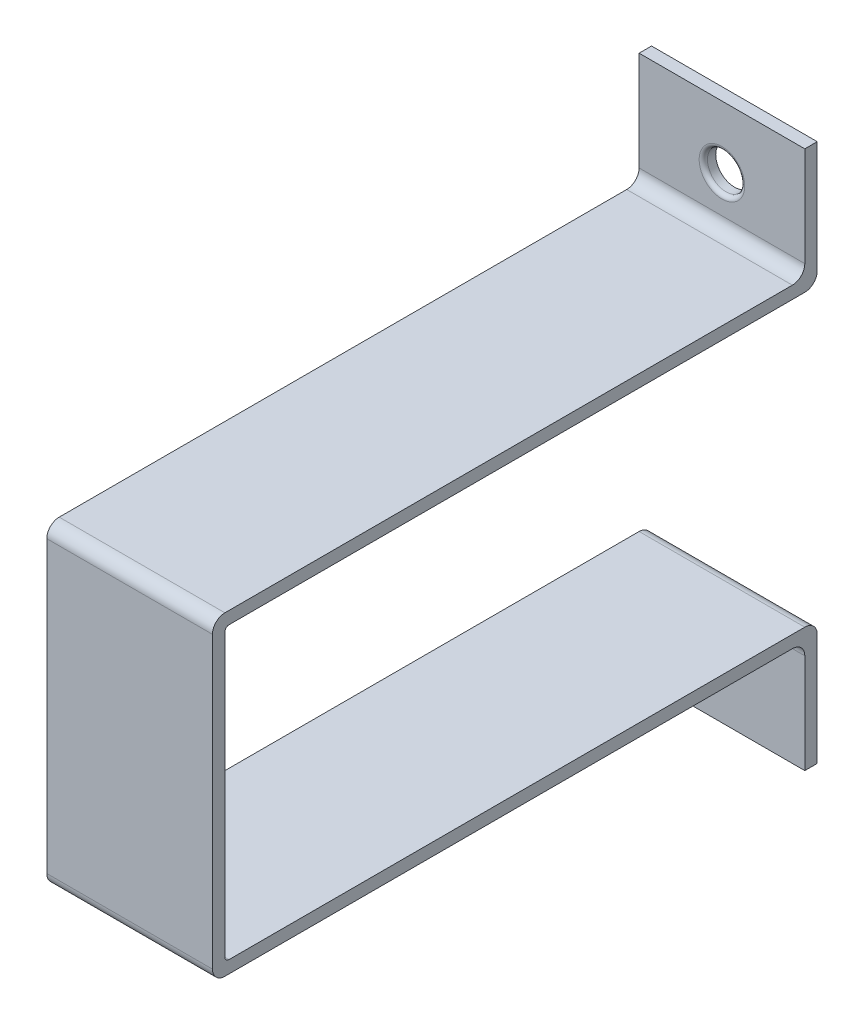
from build123d import *

# Parameters (mm, degrees)
ESQUISSE1_W             = 40
ESQUISSE1_H             = 70
BOSS_EXTRU_1_DEPTH      = 3
ESQUISSE4_W             = 40
ESQUISSE4_H             = 3
BOSS_EXTRU_3_DEPTH      = 143
ESQUISSE5_W             = 40
ESQUISSE5_H             = 30
BOSS_EXTRU_4_DEPTH      = 3
ESQUISSE6_R             = 4.5
ENL_V_MAT_EXTRU_1_DEPTH = 147
CONG_1_R                = 1
CONG_2_R                = 3
CONG_3_R                = 3
CONG_4_R                = 3
CONG_5_R                = 1


with BuildPart() as part:
    # Esquisse1 → Boss.-Extru.1 (new body)
    with BuildSketch(Plane.XY):
        Rectangle(ESQUISSE1_W, ESQUISSE1_H)
    extrude(amount=BOSS_EXTRU_1_DEPTH)

    # Esquisse4 → Boss.-Extru.3 (add)
    with BuildSketch(Plane.XY.offset(3)):
        with Locations((0, 36.5)):
            Rectangle(ESQUISSE4_W, ESQUISSE4_H)
        with Locations((0, -36.5)):
            Rectangle(ESQUISSE4_W, ESQUISSE4_H)
    extrude(amount=-BOSS_EXTRU_3_DEPTH)

    # Esquisse5 → Boss.-Extru.4 (add)
    with BuildSketch(Plane(origin=(0, 0, -140), x_dir=(-1, 0, 0), z_dir=(0, 0, -1))):
        with Locations((0, 50)):
            Rectangle(ESQUISSE5_W, ESQUISSE5_H)
        with Locations((0, -50)):
            Rectangle(ESQUISSE5_W, ESQUISSE5_H)
    extrude(amount=BOSS_EXTRU_4_DEPTH)

    # Esquisse6 → Enlèv. mat.-Extru.1 (cut, through all)
    with BuildSketch(Plane(origin=(0, 0, -143), x_dir=(-1, 0, 0), z_dir=(0, 0, -1))):
        with Locations((0, 50)):
            Circle(ESQUISSE6_R)
        with Locations((0, -50)):
            Circle(ESQUISSE6_R)
    extrude(amount=-ENL_V_MAT_EXTRU_1_DEPTH, mode=Mode.SUBTRACT)

    # Congé1
    cong_1_edges = [part.edges().sort_by_distance(p)[0] for p in [
        (0, 35, 0),
        (0, -35, 0),
    ]]
    fillet(cong_1_edges, radius=CONG_1_R)

    # Congé2
    cong_2_edges = [part.edges().sort_by_distance(p)[0] for p in [
        (0, 38, 3),
        (0, -38, 3),
    ]]
    fillet(cong_2_edges, radius=CONG_2_R)

    # Congé3
    cong_3_edges = [part.edges().sort_by_distance(p)[0] for p in [
        (0, 38, -140),
        (0, -38, -140),
    ]]
    fillet(cong_3_edges, radius=CONG_3_R)

    # Congé4
    cong_4_edges = [part.edges().sort_by_distance(p)[0] for p in [
        (0, 35, -143),
        (0, -35, -143),
    ]]
    fillet(cong_4_edges, radius=CONG_4_R)

    # Congé5
    cong_5_edges = [part.edges().sort_by_distance(p)[0] for p in [
        (4.5, 50, -140),
        (4.5, -50, -140),
    ]]
    fillet(cong_5_edges, radius=CONG_5_R)


solid = part.part
